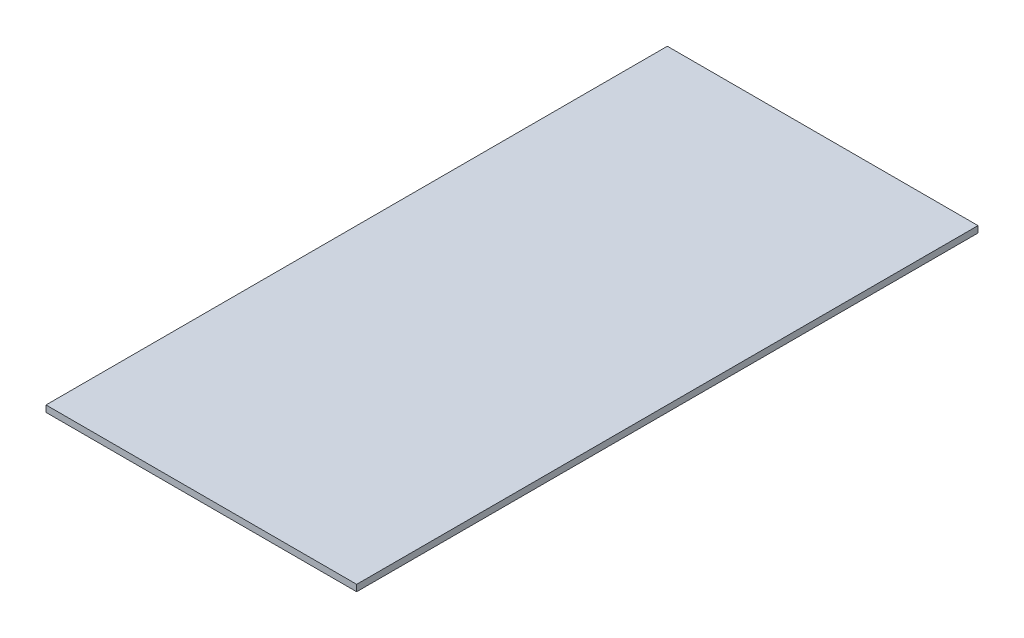
from build123d import *

# Parameters (mm, degrees)
SKETCH1_W           = 1219.2
SKETCH1_H           = 2438.4
BOSS_EXTRUDE1_DEPTH = 12.7


with BuildPart() as part:
    # Sketch1 → Boss-Extrude1 (new body, symmetric)
    with BuildSketch(Plane(origin=(0, 0, 0), x_dir=(1, 0, 0), z_dir=(0, 1, 0))):
        Rectangle(SKETCH1_W, SKETCH1_H)
    extrude(amount=BOSS_EXTRUDE1_DEPTH, both=True)


solid = part.part
